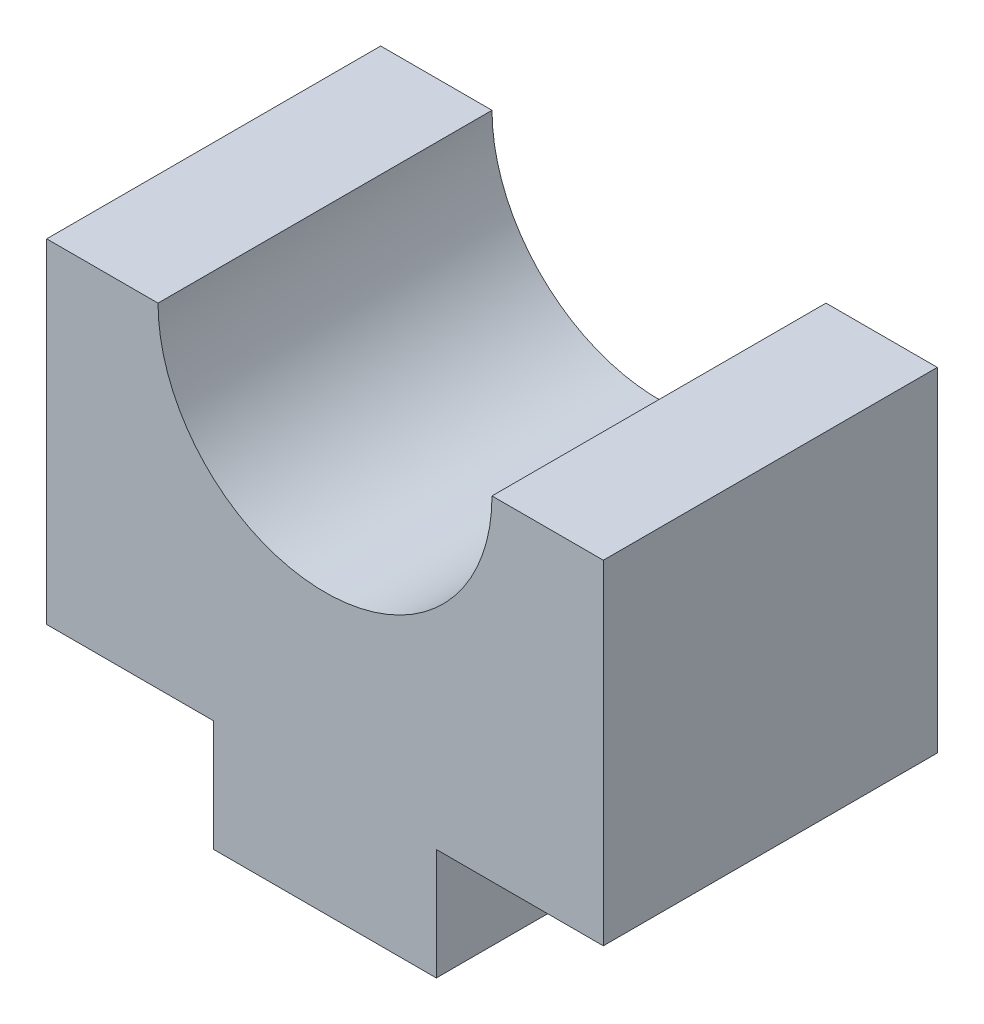
from build123d import *

# Parameters (mm, degrees)
CROQUIS1_W              = 25
CROQUIS1_H              = 15
SALIENTE_EXTRUIR1_DEPTH = 20
CROQUIS2_W              = 7.5
CROQUIS2_H              = 5
CORTAR_EXTRUIR1_DEPTH   = 20
CROQUIS3_R              = 7.5
CORTAR_EXTRUIR2_DEPTH   = 20


with BuildPart() as part:
    # Croquis1 → Saliente-Extruir1 (new body)
    with BuildSketch(Plane(origin=(0, 0, 0), x_dir=(1, 0, 0), z_dir=(0, 1, 0))):
        with Locations((12.5, -7.5)):
            Rectangle(CROQUIS1_W, CROQUIS1_H)
    extrude(amount=SALIENTE_EXTRUIR1_DEPTH)

    # Croquis2 → Cortar-Extruir1 (cut)
    with BuildSketch(Plane.XY.offset(15)):
        with Locations((21.25, 2.5)):
            Rectangle(CROQUIS2_W, CROQUIS2_H)
        with Locations((3.75, 2.5)):
            Rectangle(CROQUIS2_W, CROQUIS2_H)
    extrude(amount=-CORTAR_EXTRUIR1_DEPTH, mode=Mode.SUBTRACT)

    # Croquis3 → Cortar-Extruir2 (cut)
    with BuildSketch(Plane.XY.offset(15)):
        with Locations((12.5, 20)):
            Circle(CROQUIS3_R)
    extrude(amount=-CORTAR_EXTRUIR2_DEPTH, mode=Mode.SUBTRACT)


solid = part.part
